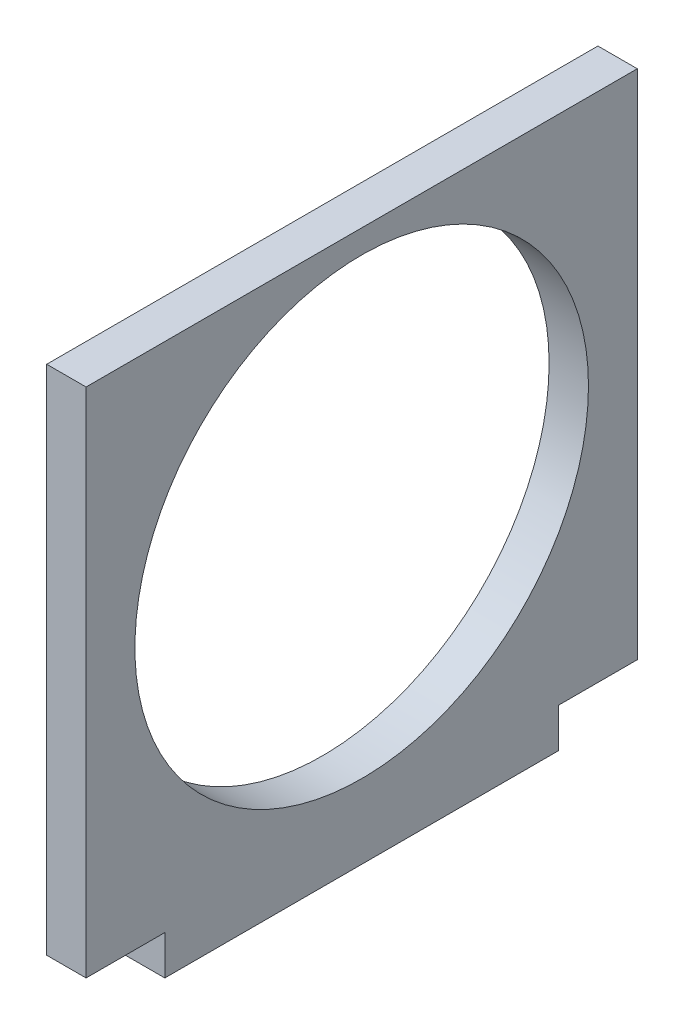
from build123d import *

# Parameters (mm, degrees)
SKETCH1_W           = 44.45
SKETCH1_H           = 44.45
BOSS_EXTRUDE1_DEPTH = 3.175
SKETCH2_R           = 18.288
SKETCH2_W           = 6.35
SKETCH2_H           = 3.175
CUT_EXTRUDE1_DEPTH  = 3.175


with BuildPart() as part:
    # Sketch1 → Boss-Extrude1 (new body)
    with BuildSketch(Plane(origin=(0, 0, 0), x_dir=(0, 0, -1), z_dir=(1, 0, 0))):
        with Locations((22.225, 22.225)):
            Rectangle(SKETCH1_W, SKETCH1_H)
    extrude(amount=BOSS_EXTRUDE1_DEPTH)

    # Sketch2 → Cut-Extrude1 (cut)
    with BuildSketch(Plane(origin=(3.175, 0, 0), x_dir=(0, 0, -1), z_dir=(1, 0, 0))):
        with Locations((22.225, 24.2697)):
            Circle(SKETCH2_R)
        with Locations((3.175, 1.5875)):
            Rectangle(SKETCH2_W, SKETCH2_H)
        with Locations((41.275, 1.5875)):
            Rectangle(SKETCH2_W, SKETCH2_H)
    extrude(amount=-CUT_EXTRUDE1_DEPTH, mode=Mode.SUBTRACT)


solid = part.part
